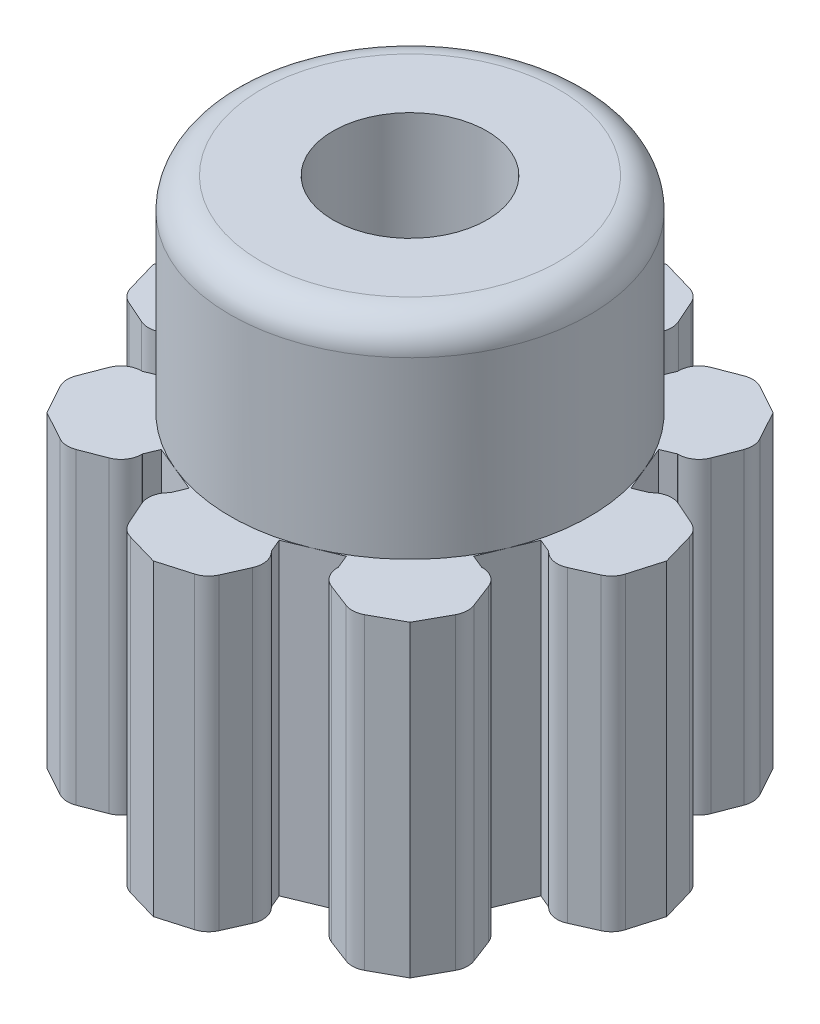
from build123d import *

# Parameters (mm, degrees)
SKETCH1_R           = 2.5
BOSS_EXTRUDE1_DEPTH = 3
SKETCH2_R           = 1.75
BOSS_EXTRUDE2_DEPTH = 2
SKETCH3_R           = 0.75
CUT_EXTRUDE1_DEPTH  = 6
SKETCH4_R           = 2.750200345
CUT_EXTRUDE3_DEPTH  = 4
SKETCH5_R           = 1.628426881
CUT_EXTRUDE4_DEPTH  = 0.1
FILLET1_R           = 0.3


with BuildPart() as part:
    # Sketch1 → Boss-Extrude1 (new body)
    with BuildSketch(Plane(origin=(0, 0, 0), x_dir=(1, 0, 0), z_dir=(0, 1, 0))):
        Circle(SKETCH1_R)
    extrude(amount=BOSS_EXTRUDE1_DEPTH)

    # Sketch2 → Boss-Extrude2 (add)
    with BuildSketch(Plane(origin=(0, 3, 0), x_dir=(1, 0, 0), z_dir=(0, 1, 0))):
        Circle(SKETCH2_R)
    extrude(amount=BOSS_EXTRUDE2_DEPTH)

    # Sketch3 → Cut-Extrude1 (cut, through all)
    with BuildSketch(Plane(origin=(0, 5, 0), x_dir=(1, 0, 0), z_dir=(0, 1, 0))):
        Circle(SKETCH3_R)
    extrude(amount=-CUT_EXTRUDE1_DEPTH, mode=Mode.SUBTRACT)

    # Sketch4 → Cut-Extrude3 (cut, through all)
    with BuildSketch(Plane(origin=(0, 3, 0), x_dir=(1, 0, 0), z_dir=(0, 1, 0))):
        Circle(SKETCH4_R)
        with BuildLine():
            Line((-1.71246004, 0.438726124), (-1.521118324, 0.90066589))
            Line((-1.521118324, 0.90066589), (-1.651645181, 0.954731884))
            Line((-1.651645181, 0.954731884), (-1.660451872, 0.954731884))
            ThreePointArc((-1.660451872, 0.954731884), (-1.773754473, 0.989921325), (-1.847186523, 1.083106679))
            Line((-1.847186523, 1.083106679), (-1.936085443, 1.314875773))
            ThreePointArc((-1.936085443, 1.314875773), (-1.948881988, 1.400186804), (-1.924557132, 1.482951682))
            Line((-1.924557132, 1.482951682), (-1.767766953, 1.767766953))
            Line((-1.767766953, 1.767766953), (-1.482951682, 1.924557132))
            ThreePointArc((-1.482951682, 1.924557132), (-1.400186804, 1.948881988), (-1.314875773, 1.936085443))
            Line((-1.314875773, 1.936085443), (-1.083106679, 1.847186523))
            ThreePointArc((-1.083106679, 1.847186523), (-0.989921325, 1.773754473), (-0.954731884, 1.660451872))
            Line((-0.954731884, 1.660451872), (-0.954731884, 1.651645181))
            Line((-0.954731884, 1.651645181), (-0.90066589, 1.521118324))
            Line((-0.90066589, 1.521118324), (-0.438726124, 1.71246004))
            Line((-0.438726124, 1.71246004), (-0.492792118, 1.842986897))
            Line((-0.492792118, 1.842986897), (-0.499019389, 1.849214168))
            ThreePointArc((-0.499019389, 1.849214168), (-0.554253735, 1.954213898), (-0.540286039, 2.072030195))
            Line((-0.540286039, 2.072030195), (-0.43926157, 2.298776721))
            ThreePointArc((-0.43926157, 2.298776721), (-0.387986085, 2.368149253), (-0.312262208, 2.409472589))
            Line((-0.312262208, 2.409472589), (0, 2.5))
            Line((0, 2.5), (0.312262208, 2.409472589))
            ThreePointArc((0.312262208, 2.409472589), (0.387986085, 2.368149253), (0.43926157, 2.298776721))
            Line((0.43926157, 2.298776721), (0.540286039, 2.072030195))
            ThreePointArc((0.540286039, 2.072030195), (0.554253735, 1.954213898), (0.499019389, 1.849214168))
            Line((0.499019389, 1.849214168), (0.492792118, 1.842986897))
            Line((0.492792118, 1.842986897), (0.438726124, 1.71246004))
            Line((0.438726124, 1.71246004), (0.90066589, 1.521118324))
            Line((0.90066589, 1.521118324), (0.954731884, 1.651645181))
            Line((0.954731884, 1.651645181), (0.954731884, 1.660451872))
            ThreePointArc((0.954731884, 1.660451872), (0.989921325, 1.773754473), (1.083106679, 1.847186523))
            Line((1.083106679, 1.847186523), (1.314875773, 1.936085443))
            ThreePointArc((1.314875773, 1.936085443), (1.400186804, 1.948881988), (1.482951682, 1.924557132))
            Line((1.482951682, 1.924557132), (1.767766953, 1.767766953))
            Line((1.767766953, 1.767766953), (1.924557132, 1.482951682))
            ThreePointArc((1.924557132, 1.482951682), (1.948881988, 1.400186804), (1.936085443, 1.314875773))
            Line((1.936085443, 1.314875773), (1.847186523, 1.083106679))
            ThreePointArc((1.847186523, 1.083106679), (1.773754473, 0.989921325), (1.660451872, 0.954731884))
            Line((1.660451872, 0.954731884), (1.651645181, 0.954731884))
            Line((1.651645181, 0.954731884), (1.521118324, 0.90066589))
            Line((1.521118324, 0.90066589), (1.71246004, 0.438726124))
            Line((1.71246004, 0.438726124), (1.842986897, 0.492792118))
            Line((1.842986897, 0.492792118), (1.849214168, 0.499019389))
            ThreePointArc((1.849214168, 0.499019389), (1.954213898, 0.554253735), (2.072030195, 0.540286039))
            Line((2.072030195, 0.540286039), (2.298776721, 0.43926157))
            ThreePointArc((2.298776721, 0.43926157), (2.368149253, 0.387986085), (2.409472589, 0.312262208))
            Line((2.409472589, 0.312262208), (2.5, 0))
            Line((2.5, 0), (2.409472589, -0.312262208))
            ThreePointArc((2.409472589, -0.312262208), (2.368149253, -0.387986085), (2.298776721, -0.43926157))
            Line((2.298776721, -0.43926157), (2.072030195, -0.540286039))
            ThreePointArc((2.072030195, -0.540286039), (1.954213898, -0.554253735), (1.849214168, -0.499019389))
            Line((1.849214168, -0.499019389), (1.842986897, -0.492792118))
            Line((1.842986897, -0.492792118), (1.71246004, -0.438726124))
            Line((1.71246004, -0.438726124), (1.521118324, -0.90066589))
            Line((1.521118324, -0.90066589), (1.651645181, -0.954731884))
            Line((1.651645181, -0.954731884), (1.660451872, -0.954731884))
            ThreePointArc((1.660451872, -0.954731884), (1.773754473, -0.989921325), (1.847186523, -1.083106679))
            Line((1.847186523, -1.083106679), (1.936085443, -1.314875773))
            ThreePointArc((1.936085443, -1.314875773), (1.948881988, -1.400186804), (1.924557132, -1.482951682))
            Line((1.924557132, -1.482951682), (1.767766953, -1.767766953))
            Line((1.767766953, -1.767766953), (1.482951682, -1.924557132))
            ThreePointArc((1.482951682, -1.924557132), (1.400186804, -1.948881988), (1.314875773, -1.936085443))
            Line((1.314875773, -1.936085443), (1.083106679, -1.847186523))
            ThreePointArc((1.083106679, -1.847186523), (0.989921325, -1.773754473), (0.954731884, -1.660451872))
            Line((0.954731884, -1.660451872), (0.954731884, -1.651645181))
            Line((0.954731884, -1.651645181), (0.90066589, -1.521118324))
            Line((0.90066589, -1.521118324), (0.438726124, -1.71246004))
            Line((0.438726124, -1.71246004), (0.492792118, -1.842986897))
            Line((0.492792118, -1.842986897), (0.499019389, -1.849214168))
            ThreePointArc((0.499019389, -1.849214168), (0.554253735, -1.954213898), (0.540286039, -2.072030195))
            Line((0.540286039, -2.072030195), (0.43926157, -2.298776721))
            ThreePointArc((0.43926157, -2.298776721), (0.387986085, -2.368149253), (0.312262208, -2.409472589))
            Line((0.312262208, -2.409472589), (0, -2.5))
            Line((0, -2.5), (-0.312262208, -2.409472589))
            ThreePointArc((-0.312262208, -2.409472589), (-0.387986085, -2.368149253), (-0.43926157, -2.298776721))
            Line((-0.43926157, -2.298776721), (-0.540286039, -2.072030195))
            ThreePointArc((-0.540286039, -2.072030195), (-0.554253735, -1.954213898), (-0.499019389, -1.849214168))
            Line((-0.499019389, -1.849214168), (-0.492792118, -1.842986897))
            Line((-0.492792118, -1.842986897), (-0.438726124, -1.71246004))
            Line((-0.438726124, -1.71246004), (-0.90066589, -1.521118324))
            Line((-0.90066589, -1.521118324), (-0.954731884, -1.651645181))
            Line((-0.954731884, -1.651645181), (-0.954731884, -1.660451872))
            ThreePointArc((-0.954731884, -1.660451872), (-0.989921325, -1.773754473), (-1.083106679, -1.847186523))
            Line((-1.083106679, -1.847186523), (-1.314875773, -1.936085443))
            ThreePointArc((-1.314875773, -1.936085443), (-1.400186804, -1.948881988), (-1.482951682, -1.924557132))
            Line((-1.482951682, -1.924557132), (-1.767766953, -1.767766953))
            Line((-1.767766953, -1.767766953), (-1.924557132, -1.482951682))
            ThreePointArc((-1.924557132, -1.482951682), (-1.948881988, -1.400186804), (-1.936085443, -1.314875773))
            Line((-1.936085443, -1.314875773), (-1.847186523, -1.083106679))
            ThreePointArc((-1.847186523, -1.083106679), (-1.773754473, -0.989921325), (-1.660451872, -0.954731884))
            Line((-1.660451872, -0.954731884), (-1.651645181, -0.954731884))
            Line((-1.651645181, -0.954731884), (-1.521118324, -0.90066589))
            Line((-1.521118324, -0.90066589), (-1.71246004, -0.438726124))
            Line((-1.71246004, -0.438726124), (-1.842986897, -0.492792118))
            Line((-1.842986897, -0.492792118), (-1.849214168, -0.499019389))
            ThreePointArc((-1.849214168, -0.499019389), (-1.954213898, -0.554253735), (-2.072030195, -0.540286039))
            Line((-2.072030195, -0.540286039), (-2.298776721, -0.43926157))
            ThreePointArc((-2.298776721, -0.43926157), (-2.368149253, -0.387986085), (-2.409472589, -0.312262208))
            Line((-2.409472589, -0.312262208), (-2.5, 0))
            Line((-2.5, 0), (-2.409472589, 0.312262208))
            ThreePointArc((-2.409472589, 0.312262208), (-2.368149253, 0.387986085), (-2.298776721, 0.43926157))
            Line((-2.298776721, 0.43926157), (-2.072030195, 0.540286039))
            ThreePointArc((-2.072030195, 0.540286039), (-1.954213898, 0.554253735), (-1.849214168, 0.499019389))
            Line((-1.849214168, 0.499019389), (-1.842986897, 0.492792118))
            Line((-1.842986897, 0.492792118), (-1.71246004, 0.438726124))
        make_face(mode=Mode.SUBTRACT)
    extrude(amount=-CUT_EXTRUDE3_DEPTH, mode=Mode.SUBTRACT)

    # Sketch5 → Cut-Extrude4 (cut)
    with BuildSketch(Plane.XZ):
        Circle(SKETCH5_R)
    extrude(amount=-CUT_EXTRUDE4_DEPTH, mode=Mode.SUBTRACT)

    # Fillet1
    fillet1_edges = [part.edges().sort_by_distance(p)[0] for p in [
        (-1.75, 5, 0),
    ]]
    fillet(fillet1_edges, radius=FILLET1_R)


solid = part.part
